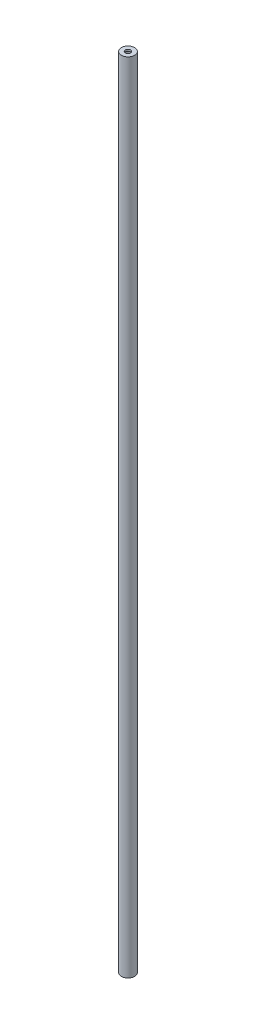
from build123d import *

# Parameters (mm, degrees)
SKETCH3_R               = 7.5
BOSS_EXTRUDE1_DEPTH     = 900
SHELL2_T                = 2
SKETCH4_R               = 3
CUT_EXTRUDE1_DEPTH      = 1
CUT_EXTRUDE1_DEPTH_BACK = 901


with BuildPart() as part:
    # Sketch3 → Boss-Extrude1 (new body)
    with BuildSketch(Plane(origin=(0, 0, 0), x_dir=(1, 0, 0), z_dir=(0, 1, 0))):
        Circle(SKETCH3_R)
    extrude(amount=BOSS_EXTRUDE1_DEPTH)

    # Shell2 (no face opened: a closed hollow body)
    add(offset(amount=-SHELL2_T, mode=Mode.PRIVATE), mode=Mode.SUBTRACT)

    # Sketch4 → Cut-Extrude1 (cut, two sides)
    with BuildSketch(Plane(origin=(0, 900, 0), x_dir=(1, 0, 0), z_dir=(0, 1, 0))) as cut_extrude1_sk:
        Circle(SKETCH4_R)
    extrude(amount=CUT_EXTRUDE1_DEPTH, mode=Mode.SUBTRACT)
    extrude(cut_extrude1_sk.sketch, amount=-CUT_EXTRUDE1_DEPTH_BACK, mode=Mode.SUBTRACT)


solid = part.part
